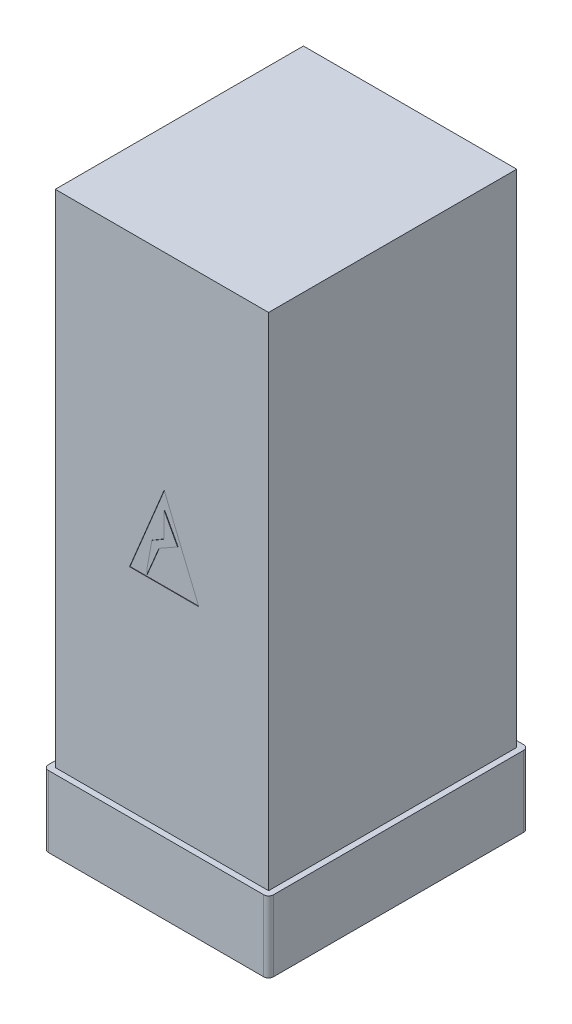
from build123d import *

# Parameters (mm, degrees)
CROQUIS1_W              = 900
CROQUIS1_H              = 1047
SALIENTE_EXTRUIR1_DEPTH = 2113
VACIADO2_T              = -10
CROQUIS2_W              = 880
CROQUIS2_H              = 2093
SALIENTE_EXTRUIR2_DEPTH = 5
CORTAR_EXTRUIR1_DEPTH   = 2
SALIENTE_EXTRUIR3_DEPTH = 300


with BuildPart() as part:
    # Croquis1 → Saliente-Extruir1 (new body)
    with BuildSketch(Plane(origin=(0, 0, 0), x_dir=(1, 0, 0), z_dir=(0, 1, 0))):
        Rectangle(CROQUIS1_W, CROQUIS1_H)
    extrude(amount=SALIENTE_EXTRUIR1_DEPTH)

    # Vaciado2
    vaciado2_openings = [part.faces().sort_by_distance(p)[0] for p in [
        (0, 1056.5, 523.5),
    ]]
    offset(amount=VACIADO2_T, openings=vaciado2_openings, kind=Kind.INTERSECTION)

    # Croquis2 → Saliente-Extruir2 (add)
    with BuildSketch(Plane.XY.offset(523.5)):
        with Locations((0, 1056.5)):
            Rectangle(CROQUIS2_W, CROQUIS2_H)
    extrude(amount=-SALIENTE_EXTRUIR2_DEPTH)

    # Croquis3 → Cortar-Extruir1 (cut)
    with BuildSketch(Plane.XY.offset(523.5)):
        Polygon((-136.509991439, 890.520139483), (155.469712472, 890.520139483), (9.479860517, 1243.170950701), align=None)
        Polygon((-63.176808732, 920.19459615), (-42.169545822, 1034.041849102), (9.479860517, 1064.169920858), (9.479860517, 1169.411963853), (65.966344659, 1064.169920858), (-12.532301764, 1019.623730372), (-63.176808732, 898.913148296), align=None, mode=Mode.SUBTRACT)
    extrude(amount=-CORTAR_EXTRUIR1_DEPTH, mode=Mode.SUBTRACT)

    # Croquis4 → Saliente-Extruir3 (add)
    with BuildSketch(Plane.XZ):
        with BuildLine():
            Line((-454.35645152, 548.5), (454.35645152, 548.5))
            ThreePointArc((454.35645152, 548.5), (468.953644638, 542.453644638), (475, 527.85645152))
            Line((475, 527.85645152), (475, -527.85645152))
            ThreePointArc((475, -527.85645152), (468.953644638, -542.453644638), (454.35645152, -548.5))
            Line((454.35645152, -548.5), (-454.35645152, -548.5))
            ThreePointArc((-454.35645152, -548.5), (-468.953644638, -542.453644638), (-475, -527.85645152))
            Line((-475, -527.85645152), (-475, 527.85645152))
            ThreePointArc((-475, 527.85645152), (-468.953644638, 542.453644638), (-454.35645152, 548.5))
        make_face()
    extrude(amount=SALIENTE_EXTRUIR3_DEPTH)


solid = part.part
